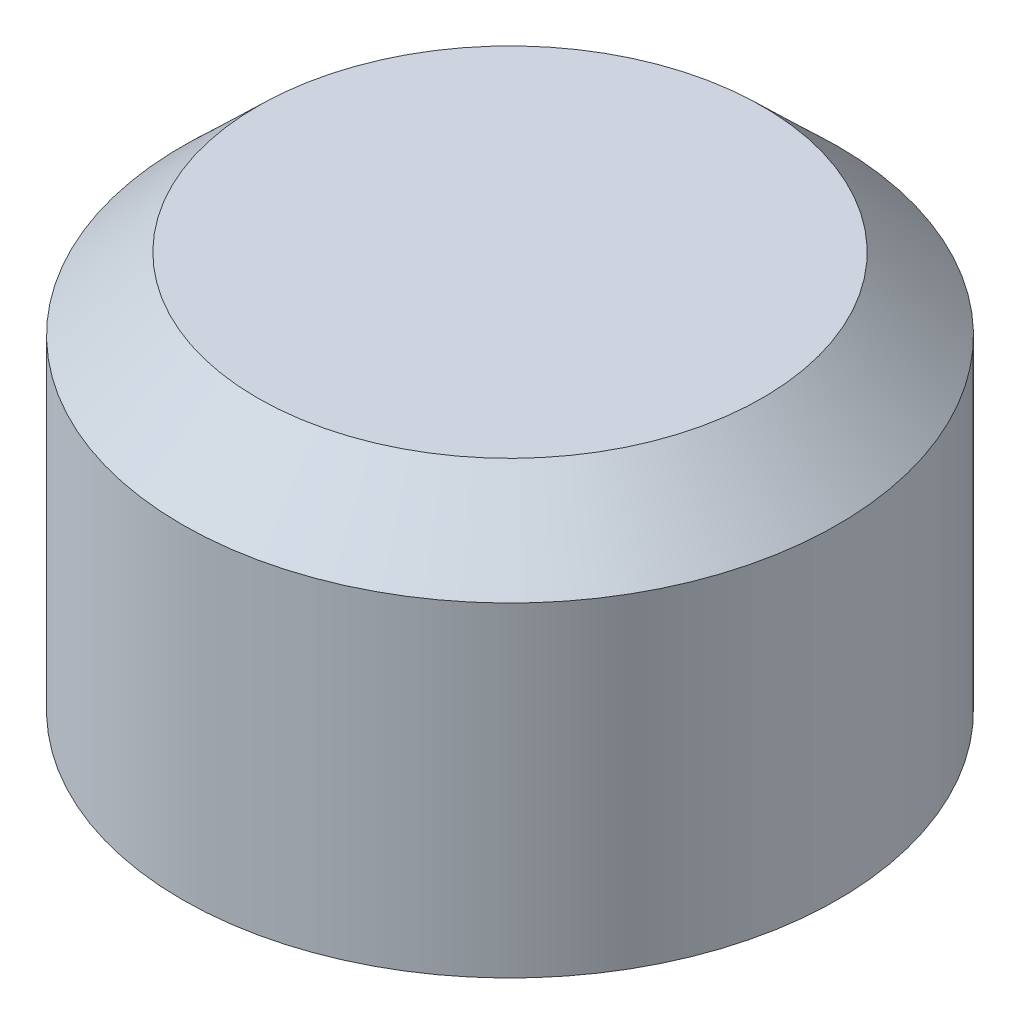
from build123d import *


with BuildPart() as part:
    # Sketch1 → Revolve1 (revolve)
    with BuildSketch(Plane.XY):
        Polygon((-2438.4, 0), (-2438.4, 2753.721024484), (-2118.721024484, 3073.4), (-1190.8772065, 3073.4), (-914.4, 2796.9227935), (-914.4, 2074), (-597.031176681, 1524.301073273), (-622.431176681, 1524.301073273), (-939.8, 2074), (-939.8, 2786.401769016), (-1201.398230984, 3048), (-2108.2, 3048), (-2413, 2743.2), (-2413, 0), align=None)
    revolve(axis=Axis((0, 3520.44, 0), (0, -1, 0)))


with BuildPart() as body_2:
    # Sketch2 → Revolve2 (revolve)
    with BuildSketch(Plane.XY):
        Polygon((-2743.2, 0), (-2768.6, 0), (-2768.6, 2743.2), (-2133.6, 3352.8), (0, 3352.8), (0, 3327.4), (-2123.381318695, 3327.4), (-2743.2, 2732.374065947), align=None)
    revolve(axis=Axis((0, 3520.44, 0), (0, -1, 0)))


solid = Compound([part.part, body_2.part])
